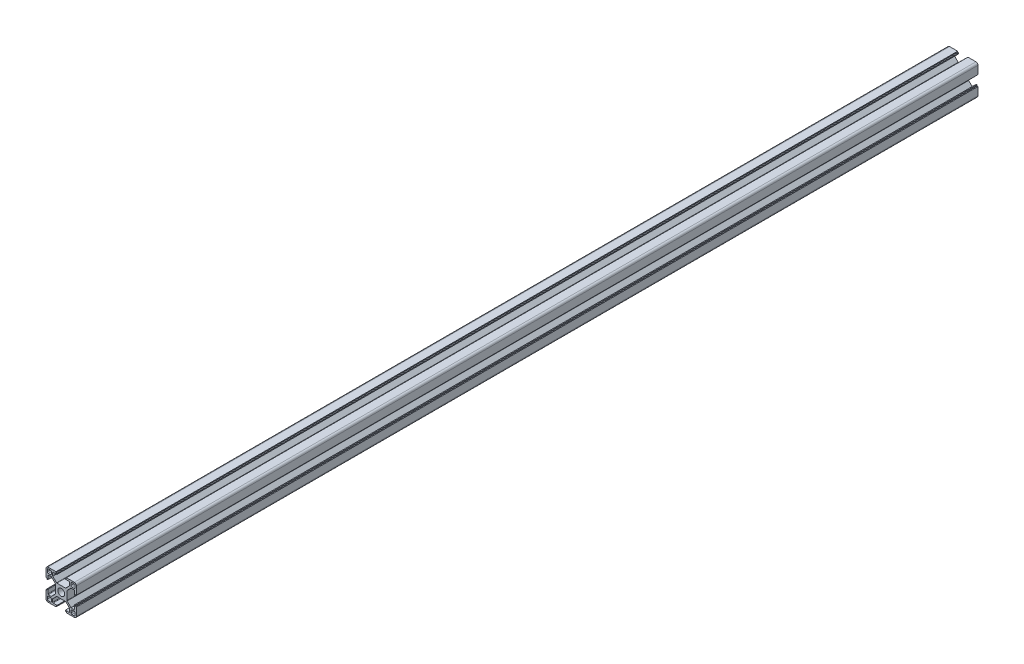
from build123d import *

# Parameters (mm, degrees)
SKETCH_1_W                       = 4
SKETCH_1_H                       = 4
EXTRUDE_1_DEPTH                  = 890
FILLET_1_R                       = 1
FILLET_2_R                       = 2
FILLET_3_R                       = 0.5
PATTERN_CIRCULAR_1_COUNT         = 4
FILLET_1_OF_PATTERN_CIRCULAR_1_R = 1
FILLET_2_OF_PATTERN_CIRCULAR_1_R = 2
FILLET_3_OF_PATTERN_CIRCULAR_1_R = 0.5
SKETCH_2_R                       = 3.4
CUT_EXTRUDE_1_DEPTH              = 891
SKETCH_3_R                       = 3.05
SKETCH_3_R_2                     = 4.05
CUT_EXTRUDE_2_DEPTH              = 10


with BuildPart() as part:
    # 草图1 → 凸台-拉伸1 (new body)
    with BuildSketch(Plane.XY):
        Polygon((5.7, 0), (5.7, 4.427207794), (9.672792206, 8.4), (13.2, 8.4), (13.2, 4.1), (14.1, 4.1), (14.1, 5.1), (15, 5.1), (15, 15), (5.1, 15), (5.1, 14.1), (4.1, 14.1), (4.1, 13.2), (8.4, 13.2), (8.4, 9.672792206), (4.427207794, 5.7), (0, 5.7), (0, 0), align=None)
        with Locations((11.7, 11.7)):
            Rectangle(SKETCH_1_W, SKETCH_1_H, mode=Mode.SUBTRACT)
    extrude_1 = extrude(amount=EXTRUDE_1_DEPTH)

    # 圆角1
    fillet_1_edges = [part.edges().sort_by_distance(p)[0] for p in [
        (13.7, 9.7, 445),
        (13.7, 13.7, 445),
        (9.7, 13.7, 445),
        (9.7, 9.7, 445),
    ]]
    fillet(fillet_1_edges, radius=FILLET_1_R)

    # 圆角2
    fillet_2_edges = [part.edges().sort_by_distance(p)[0] for p in [
        (15, 15, 445),
    ]]
    fillet(fillet_2_edges, radius=FILLET_2_R)

    # 圆角3
    fillet_3_edges = [part.edges().sort_by_distance(p)[0] for p in [
        (4.427207794, 5.7, 445),
        (8.4, 9.672792206, 445),
        (8.4, 13.2, 445),
        (13.2, 8.4, 445),
        (9.672792206, 8.4, 445),
        (5.7, 4.427207794, 445),
    ]]
    fillet(fillet_3_edges, radius=FILLET_3_R)

    # 阵列(圆周)1: 凸台-拉伸1 ×4 about axis
    pattern_circular_1_axis = Axis((0, 0, 0), (0, 0, 1))
    for i in range(1, PATTERN_CIRCULAR_1_COUNT):
        add(extrude_1.rotate(pattern_circular_1_axis, i * 360 / PATTERN_CIRCULAR_1_COUNT))

    # 圆角1 of 阵列(圆周)1
    fillet_1_of_pattern_circular_1_edges = [part.edges().sort_by_distance(p)[0] for p in [
        (-9.7, 13.7, 445),
        (-13.7, 13.7, 445),
        (-13.7, 9.7, 445),
        (-9.7, 9.7, 445),
        (-13.7, -9.7, 445),
        (-13.7, -13.7, 445),
        (-9.7, -13.7, 445),
        (-9.7, -9.7, 445),
        (9.7, -13.7, 445),
        (13.7, -13.7, 445),
        (13.7, -9.7, 445),
        (9.7, -9.7, 445),
    ]]
    fillet(fillet_1_of_pattern_circular_1_edges, radius=FILLET_1_OF_PATTERN_CIRCULAR_1_R)

    # 圆角2 of 阵列(圆周)1
    fillet_2_of_pattern_circular_1_edges = [part.edges().sort_by_distance(p)[0] for p in [
        (-15, 15, 445),
        (-15, -15, 445),
        (15, -15, 445),
    ]]
    fillet(fillet_2_of_pattern_circular_1_edges, radius=FILLET_2_OF_PATTERN_CIRCULAR_1_R)

    # 圆角3 of 阵列(圆周)1
    fillet_3_of_pattern_circular_1_edges = [part.edges().sort_by_distance(p)[0] for p in [
        (-5.7, 4.427207794, 445),
        (-9.672792206, 8.4, 445),
        (-13.2, 8.4, 445),
        (-8.4, 13.2, 445),
        (-8.4, 9.672792206, 445),
        (-4.427207794, 5.7, 445),
        (-4.427207794, -5.7, 445),
        (-8.4, -9.672792206, 445),
        (-8.4, -13.2, 445),
        (-13.2, -8.4, 445),
        (-9.672792206, -8.4, 445),
        (-5.7, -4.427207794, 445),
        (5.7, -4.427207794, 445),
        (9.672792206, -8.4, 445),
        (13.2, -8.4, 445),
        (8.4, -13.2, 445),
        (8.4, -9.672792206, 445),
        (4.427207794, -5.7, 445),
    ]]
    fillet(fillet_3_of_pattern_circular_1_edges, radius=FILLET_3_OF_PATTERN_CIRCULAR_1_R)

    # 草图2 → 切除-拉伸1 (cut, through all)
    with BuildSketch(Plane.XY.offset(890)):
        Circle(SKETCH_2_R)
    extrude(amount=-CUT_EXTRUDE_1_DEPTH, mode=Mode.SUBTRACT)

    # 草图3 → 切除-拉伸2 (cut, symmetric)
    with BuildSketch(Plane(origin=(0, 0, 0), x_dir=(0, 0, -1), z_dir=(1, 0, 0))):
        with Locations((-15, 0)):
            Circle(SKETCH_3_R)
        with Locations((-875, 0)):
            Circle(SKETCH_3_R)
        with Locations((-595, 0)):
            Circle(SKETCH_3_R_2)
    extrude(amount=CUT_EXTRUDE_2_DEPTH, both=True, mode=Mode.SUBTRACT)


solid = part.part
